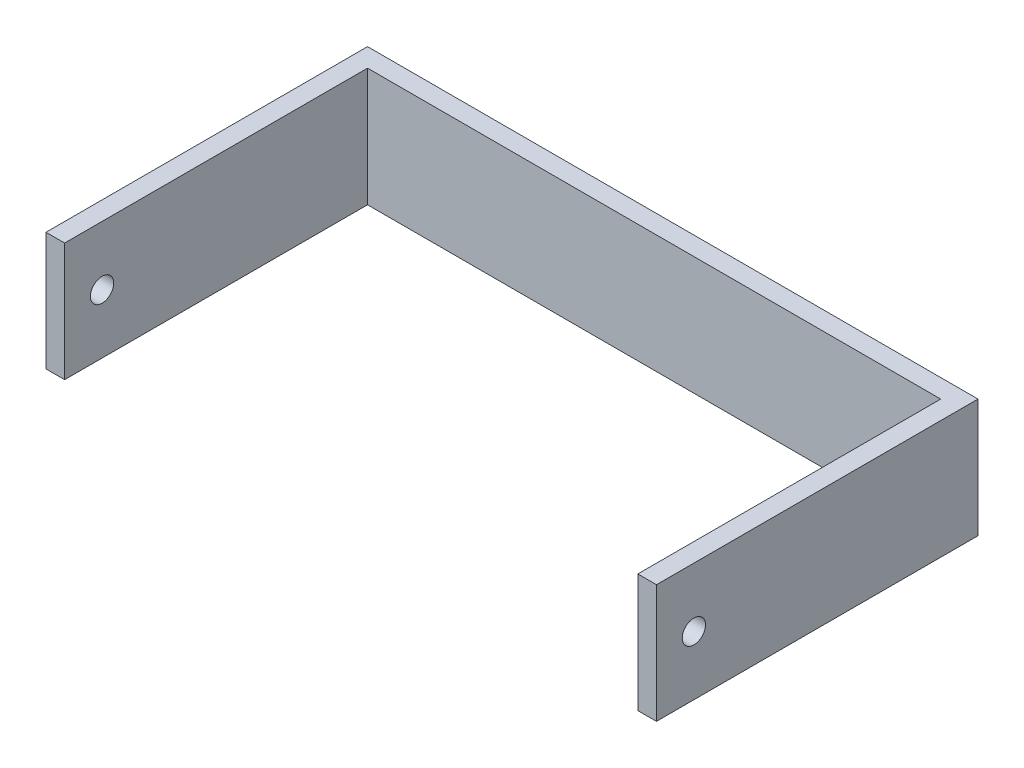
from build123d import *

# Parameters (mm, degrees)
SALIENTE_EXTRUIR1_DEPTH    = 25.4
CROQUIS3_R                 = 2.5
CORTAR_EXTRUIR1_DEPTH      = 1
CORTAR_EXTRUIR1_DEPTH_BACK = 132


with BuildPart() as part:
    # Croquis1 → Saliente-Extruir1 (new body)
    with BuildSketch(Plane(origin=(0, 0, 0), x_dir=(1, 0, 0), z_dir=(0, 1, 0))):
        Polygon((-71.71783911, 0), (51.28216089, 0), (51.28216089, -65), (55.28216089, -65), (55.28216089, 4), (-75.71783911, 4), (-75.71783911, -65), (-71.71783911, -65), align=None)
    extrude(amount=SALIENTE_EXTRUIR1_DEPTH)

    # Croquis3 → Cortar-Extruir1 (cut, two sides)
    with BuildSketch(Plane(origin=(55.28216089, 0, 0), x_dir=(0, 0, -1), z_dir=(1, 0, 0))) as cortar_extruir1_sk:
        with Locations((-56.969231592, 12.7)):
            Circle(CROQUIS3_R)
    extrude(amount=CORTAR_EXTRUIR1_DEPTH, mode=Mode.SUBTRACT)
    extrude(cortar_extruir1_sk.sketch, amount=-CORTAR_EXTRUIR1_DEPTH_BACK, mode=Mode.SUBTRACT)


solid = part.part
